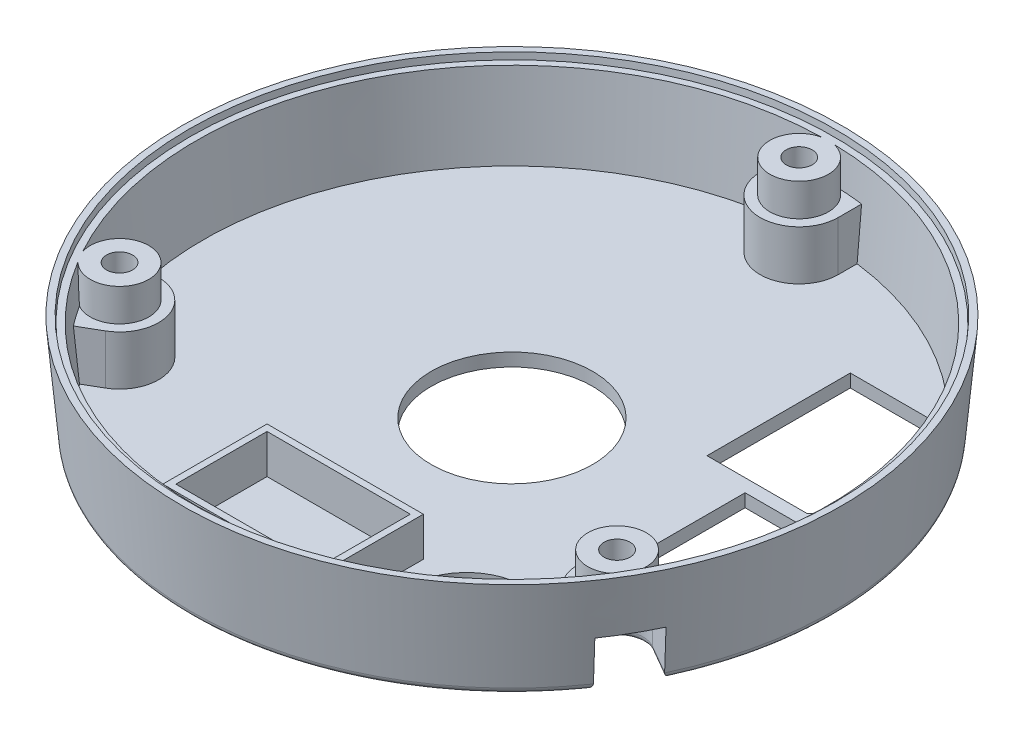
from build123d import *

# Parameters (mm, degrees)
SKETCH_8_R               = 2.25
EXTRUDE_23_DEPTH         = 6.3
EXTRUDE_24_DEPTH         = 3.8
CUT_EXTRUDE_START        = -2
SKETCH_8_5_R             = 1
CUT_EXTRUDE_2_DEPTH      = 9.8
PATTERN_CIRCULAR_1_COUNT = 3
CUT_EXTRUDE_3_DEPTH      = 3.7
PATTERN_CIRCULAR_2_COUNT = 3
CUT_EXTRUDE_6_DEPTH      = 1
SKETCH_12_W              = 12
SKETCH_12_H              = 8
SKETCH_12_W_2            = 11
SKETCH_12_H_2            = 7
EXTRUDE_1_DEPTH          = 3
SKETCH_14_R              = 6.2
SKETCH_14_R_2            = 4.5
CUT_EXTRUDE_7_DEPTH      = 1
FILLET_1_R               = 0.5


with BuildPart() as part:
    # 草图7 → 旋转1 (revolve)
    with BuildSketch(Plane.XY):
        Polygon((0, 0), (24.6, 0), (25.3, 7.8), (24.8, 7.8), (24.755128205, 7.3), (24.255128205, 7.3), (23.68974359, 1), (0, 1), align=None)
    revolve(axis=Axis((0, 1, 0), (0, -1, 0)))

    # 草图8 → 凸台-拉伸23 (add)
    with BuildSketch(Plane(origin=(0, 1, 0), x_dir=(1, 0, 0), z_dir=(0, 1, 0))):
        with Locations((0, 22.05)):
            Circle(SKETCH_8_R)
    extrude_23 = extrude(amount=EXTRUDE_23_DEPTH)

    # 草图8<4> → 凸台-拉伸24 (add)
    with BuildSketch(Plane(origin=(0, 1, 0), x_dir=(1, 0, 0), z_dir=(0, 1, 0))):
        with BuildLine():
            Line((-3, 22.05), (-3, 24.114103757))
            ThreePointArc((-3, 24.114103757), (0, 24.3), (3, 24.114103757))
            Line((3, 24.114103757), (3, 22.05))
            ThreePointArc((3, 22.05), (0, 19.05), (-3, 22.05))
        make_face()
    extrude_24 = extrude(amount=EXTRUDE_24_DEPTH)

    # 草图8<5> → 切除-拉伸2 (cut)
    with BuildSketch(Plane(origin=(0, 1, 0), x_dir=(1, 0, 0), z_dir=(0, 1, 0)).offset(CUT_EXTRUDE_START)):
        with Locations((0, 22.05)):
            Circle(SKETCH_8_5_R)
    cut_extrude_2 = extrude(amount=CUT_EXTRUDE_2_DEPTH, mode=Mode.SUBTRACT)

    # 阵列(圆周)1: 凸台-拉伸23, 凸台-拉伸24, 切除-拉伸2 ×3 about axis
    pattern_circular_1_axis = Axis((0, 0, 0), (0, 1, 0))
    for i in range(1, PATTERN_CIRCULAR_1_COUNT):
        add(extrude_23.rotate(pattern_circular_1_axis, i * 360 / PATTERN_CIRCULAR_1_COUNT))
        add(extrude_24.rotate(pattern_circular_1_axis, i * 360 / PATTERN_CIRCULAR_1_COUNT))
        add(cut_extrude_2.rotate(pattern_circular_1_axis, i * 360 / PATTERN_CIRCULAR_1_COUNT), mode=Mode.SUBTRACT)

    # 草图9 → 切除-拉伸3 (cut)
    with BuildSketch(Plane.XZ):
        with BuildLine():
            Line((2, -22.05), (2, -26.095171051))
            Line((2, -26.095171051), (-2, -26.095171051))
            Line((-2, -26.095171051), (-2, -22.05))
            ThreePointArc((-2, -22.05), (0, -20.05), (2, -22.05))
        make_face()
    cut_extrude_3 = extrude(amount=-CUT_EXTRUDE_3_DEPTH, mode=Mode.SUBTRACT)

    # 阵列(圆周)2: 切除-拉伸3 ×3 about axis
    pattern_circular_2_axis = Axis((0, 0, 0), (0, 1, 0))
    for i in range(1, PATTERN_CIRCULAR_2_COUNT):
        add(cut_extrude_3.rotate(pattern_circular_2_axis, i * 360 / PATTERN_CIRCULAR_2_COUNT), mode=Mode.SUBTRACT)

    # 草图11 → 切除-拉伸6 (cut)
    with BuildSketch(Plane(origin=(0, 1, 0), x_dir=(1, 0, 0), z_dir=(0, 1, 0))):
        Polygon((10, 15.975), (10, 4.975), (17.7, 4.975), (18.7, 5.975), (18.7, 14.975), (17.7, 15.975), align=None)
        Polygon((13.924175705, 3.975), (13.924175705, -7.025), (21.624175705, -7.025), (22.624175705, -6.025), (22.624175705, 2.975), (21.624175705, 3.975), align=None)
    extrude(amount=-CUT_EXTRUDE_6_DEPTH, mode=Mode.SUBTRACT)

    # 草图12 → 拉伸-薄壁1 (add)
    with BuildSketch(Plane(origin=(0, 1, 0), x_dir=(1, 0, 0), z_dir=(0, 1, 0))):
        with Locations((0, -16.8)):
            Rectangle(SKETCH_12_W, SKETCH_12_H)
        with Locations((0, -16.8)):
            Rectangle(SKETCH_12_W_2, SKETCH_12_H_2, mode=Mode.SUBTRACT)
    extrude(amount=EXTRUDE_1_DEPTH)

    # 草图14 → 切除-拉伸7 (cut)
    with BuildSketch(Plane(origin=(0, 1, 0), x_dir=(1, 0, 0), z_dir=(0, 1, 0))):
        Circle(SKETCH_14_R)
        with Locations((11.70765428, -15.20450888)):
            Circle(SKETCH_14_R_2)
    extrude(amount=-CUT_EXTRUDE_7_DEPTH, mode=Mode.SUBTRACT)

    # 圆角1
    fillet_1_edges = [part.edges().sort_by_distance(p)[0] for p in [
        (-21.304224933, 0, -12.3),
        (-2, 0, -23.284282198),
        (2, 0, -23.284282198),
        (0, 0, -20.05),
        (0, 0, 24.6),
        (18.088117647, 0, -16.67273223),
        (-19.164779892, 0, 13.374191906),
        (-21.164779892, 0, 9.910090291),
        (-17.363809346, 0, 10.025),
        (21.164779892, 0, 9.910090291),
        (19.164779892, 0, 13.374191906),
        (17.363809346, 0, 10.025),
    ]]
    fillet(fillet_1_edges, radius=FILLET_1_R)


solid = part.part
